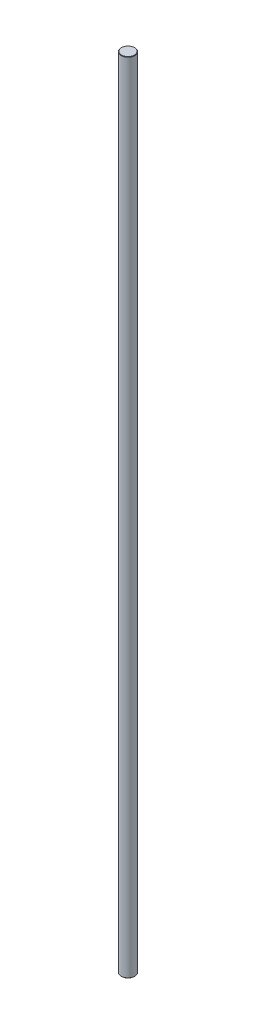
from build123d import *

# Parameters (mm, degrees)
SKETCH1_R           = 4
BOSS_EXTRUDE1_DEPTH = 235
CHAMFER1_SIZE       = 0.2


with BuildPart() as part:
    # Sketch1 → Boss-Extrude1 (new body, symmetric)
    with BuildSketch(Plane(origin=(0, 0, 0), x_dir=(1, 0, 0), z_dir=(0, 1, 0))):
        Circle(SKETCH1_R)
    extrude(amount=BOSS_EXTRUDE1_DEPTH, both=True)

    # Chamfer1
    chamfer1_edges = [part.edges().sort_by_distance(p)[0] for p in [
        (-4, -235, 0),
        (-4, 235, 0),
    ]]
    chamfer(chamfer1_edges, length=CHAMFER1_SIZE)


solid = part.part
